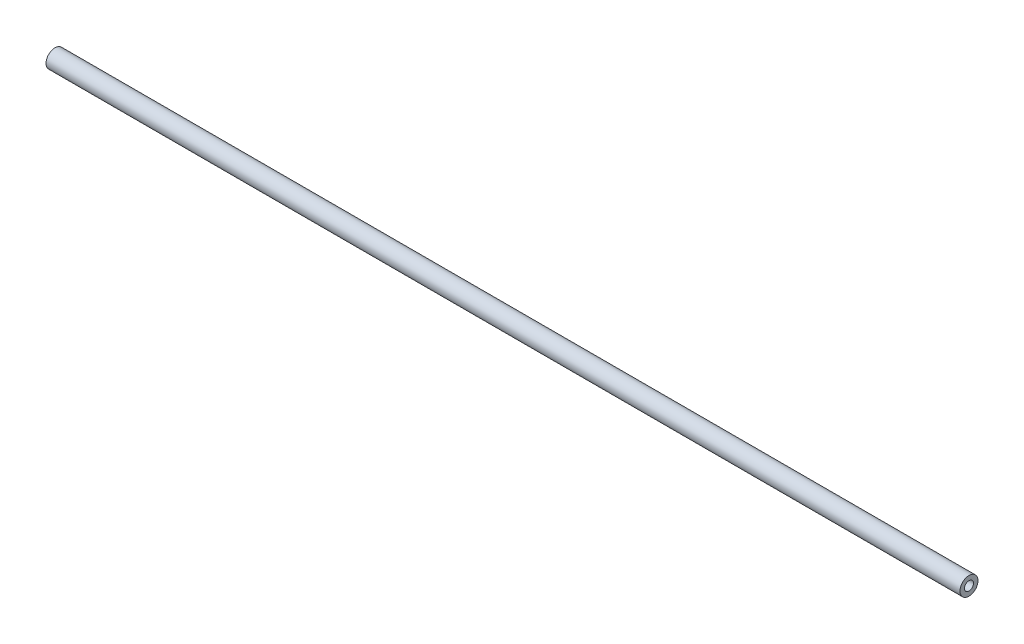
from build123d import *

# Parameters (mm, degrees)
CROQUIS1_R              = 4
CROQUIS1_R_2            = 2
SALIENTE_EXTRUIR1_DEPTH = 186.5
SKETCH1_R               = 4
SKETCH1_R_2             = 2
BOSS_EXTRUDE1_DEPTH     = 32.85


with BuildPart() as part:
    # Croquis1 → Saliente-Extruir1 (new body, symmetric)
    with BuildSketch(Plane(origin=(0, 0, 0), x_dir=(0, 0, -1), z_dir=(1, 0, 0))):
        Circle(CROQUIS1_R)
        Circle(CROQUIS1_R_2, mode=Mode.SUBTRACT)
    extrude(amount=SALIENTE_EXTRUIR1_DEPTH, both=True)

    # Sketch1 → Boss-Extrude1 (add)
    with BuildSketch(Plane.ZY.offset(186.5)):
        Circle(SKETCH1_R)
        Circle(SKETCH1_R_2, mode=Mode.SUBTRACT)
    extrude(amount=BOSS_EXTRUDE1_DEPTH)


solid = part.part
